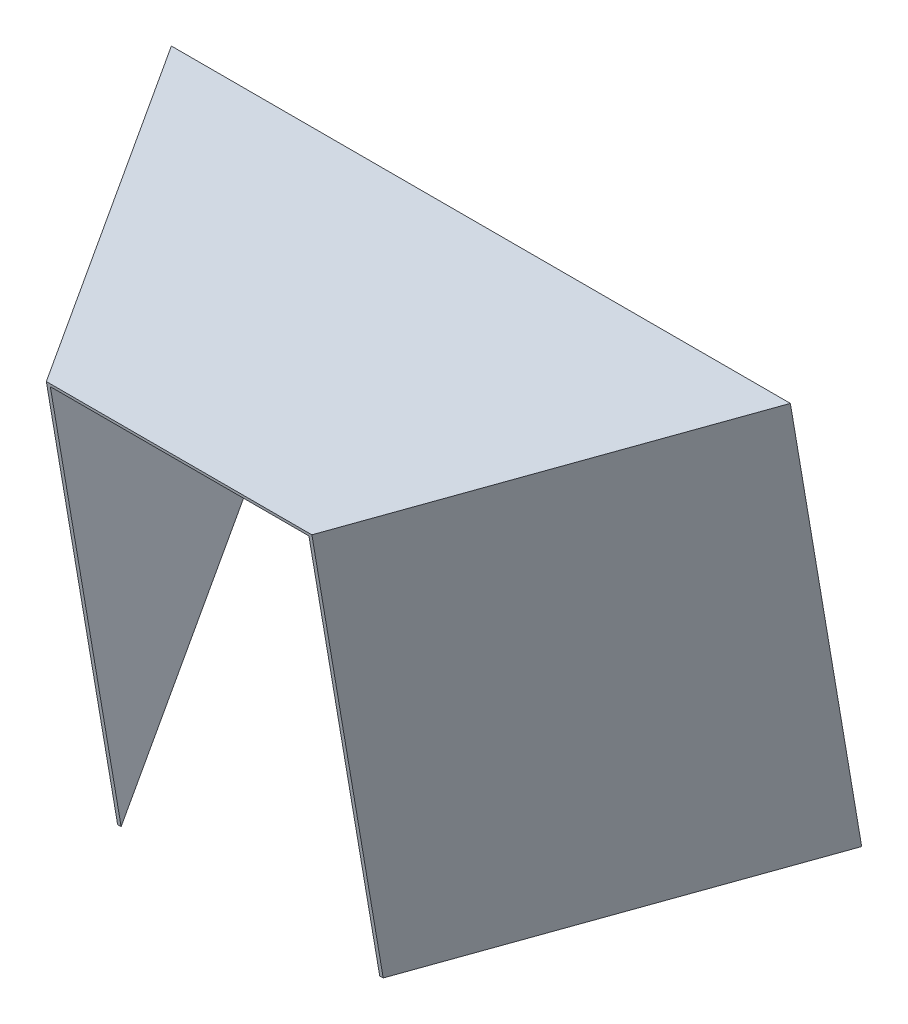
from build123d import *

# Parameters (mm, degrees)
BOSS_EXTRUDE1_DEPTH = 6.35
BOSS_EXTRUDE2_DEPTH = 6.35
CUT_EXTRUDE2_REACH  = 932.677
BOSS_EXTRUDE3_DEPTH = 889


with BuildPart() as part:
    # Sketch3 → Boss-Extrude1 (new body)
    with BuildSketch(Plane(origin=(0, 0, 0), x_dir=(0, 0, -1), z_dir=(1, 0, 0))):
        Polygon((0, 0), (635, 0), (635, 609.6), (0, 501.65), align=None)
    extrude(amount=BOSS_EXTRUDE1_DEPTH)

    # Sketch5 → Boss-Extrude2 (add)
    with BuildSketch(Plane(origin=(0, 487.559529595, 82.885120031), x_dir=(1, 0, 0), z_dir=(0, 0.985855847, 0.167595494))):
        Polygon((6.35, 84.074279532), (378.227310637, 728.184675737), (-924.327310637, 728.184675737), (-552.45, 84.074279532), align=None)
    extrude(amount=BOSS_EXTRUDE2_DEPTH)

    # Sketch10 → Cut-Extrude2 (cut, up to next)
    with BuildSketch(Plane(origin=(6.35, 0, 0), x_dir=(0, 0, -1), z_dir=(1, 0, 0)), mode=Mode.PRIVATE) as cut_extrude2_sk1:
        Polygon((0, 501.65), (0, 0), (635, 0), (635, 609.6), align=None)
    cut_extrude2_tool1 = extrude(cut_extrude2_sk1.sketch, amount=-CUT_EXTRUDE2_REACH, mode=Mode.PRIVATE) & part.part
    add(cut_extrude2_tool1.solids().sort_by_distance((6.35, 278.686381, -327.780952))[0], mode=Mode.SUBTRACT)

    # Sketch9 → Boss-Extrude3 (add)
    with BuildSketch(Plane(origin=(0, 487.559529595, 82.885120031), x_dir=(1, 0, 0), z_dir=(0, -0.985855847, -0.167595494))):
        Polygon((378.227310637, -728.184675737), (6.35, -84.074279532), (-0.982348419, -84.074279532), (370.894962218, -728.184675737), align=None)
        Polygon((-924.327310637, -728.184675737), (-552.45, -84.074279532), (-545.117651581, -84.074279532), (-916.994962218, -728.184675737), align=None)
    extrude(amount=BOSS_EXTRUDE3_DEPTH)


solid = part.part
